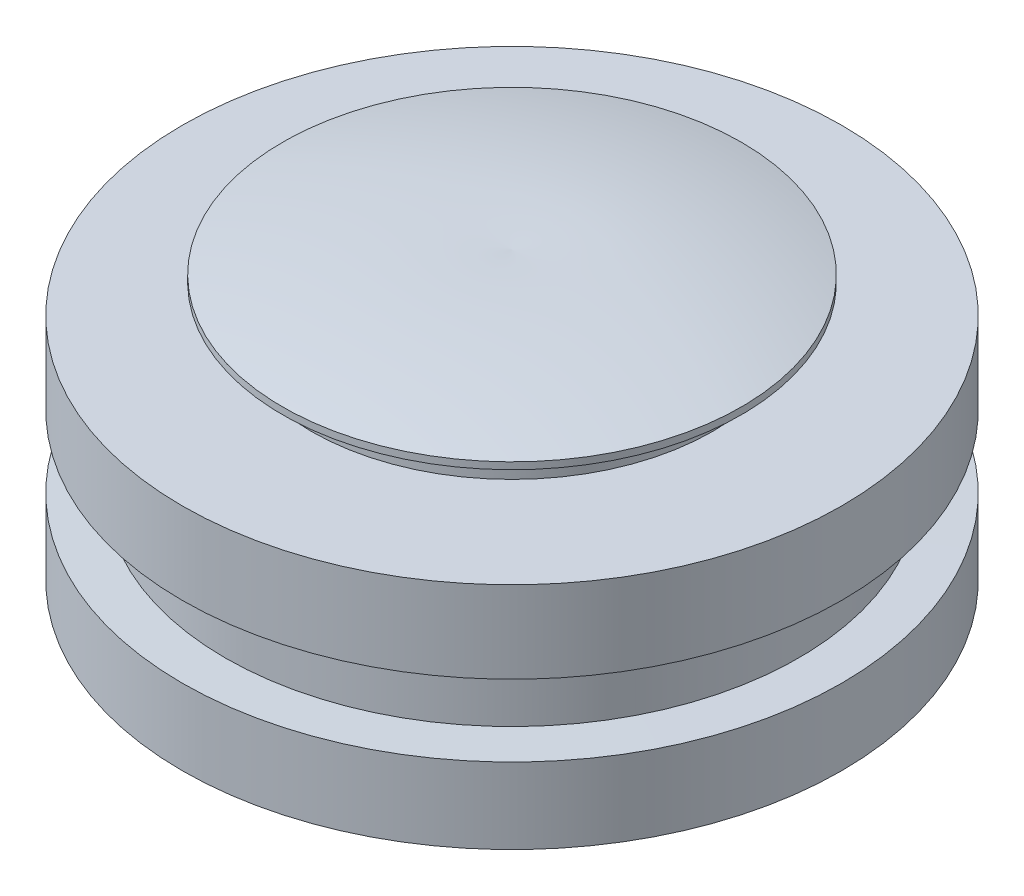
from build123d import *


with BuildPart() as part:
    # Эскиз1 → Повернуть1 (revolve)
    with BuildSketch(Plane.XY):
        with BuildLine():
            Line((11.5, -2.982243983), (11.5, -5.627433044))
            Line((11.5, -5.627433044), (6, -5.627433044))
            Line((6, -5.627433044), (6, 2.372566956))
            Line((6, 2.372566956), (0, 3.372566956))
            Line((0, 3.372566956), (0, 4.372566956))
            ThreePointArc((0, 4.372566956), (4.029595345, 4.302809639), (8, 3.611151047))
            Line((8, 3.611151047), (8, 3.372566956))
            Line((8, 3.372566956), (7, 3.372566956))
            Line((7, 3.372566956), (7, 2.372566956))
            Line((7, 2.372566956), (11.5, 2.372566956))
            Line((11.5, 2.372566956), (11.5, -0.481527002))
            Line((11.5, -0.481527002), (10, -0.470528934))
            Line((10, -0.470528934), (10, -2.971245915))
            Line((10, -2.971245915), (11.5, -2.982243983))
        make_face()
    revolve(axis=Axis((0, 3.372566956, 0), (0, 1, 0)))


solid = part.part
